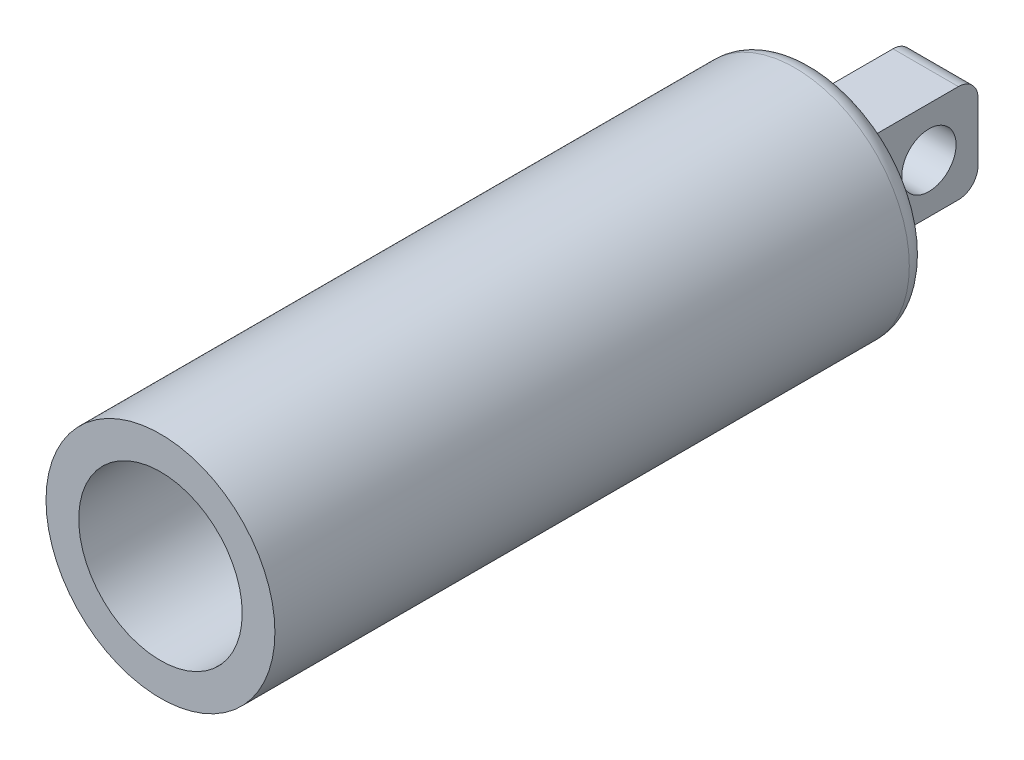
from build123d import *

# Parameters (mm, degrees)
SKETCH1_R                = 17.5
BOSS_EXTRUDE1_DEPTH      = 100
SKETCH2_R                = 12.5
CUT_EXTRUDE1_DEPTH       = 90
BOSS_EXTRUDE2_DEPTH      = 5
BOSS_EXTRUDE2_DEPTH_BACK = 5
SKETCH3_W                = 20
SKETCH3_H                = 15
SKETCH3_R                = 4.15
FILLET1_R                = 3


with BuildPart() as part:
    # Sketch1 → Boss-Extrude1 (new body)
    with BuildSketch(Plane.XY):
        Circle(SKETCH1_R)
    extrude(amount=BOSS_EXTRUDE1_DEPTH)

    # Sketch2 → Cut-Extrude1 (cut)
    with BuildSketch(Plane.XY.offset(100)):
        Circle(SKETCH2_R)
    extrude(amount=-CUT_EXTRUDE1_DEPTH, mode=Mode.SUBTRACT)

    # Sketch3 → Boss-Extrude2 (add, two sides: drawn at the far end of the back side and taken through both)
    with BuildSketch(Plane(origin=(0, 0, 0), x_dir=(0, 0, -1), z_dir=(1, 0, 0)).offset(-BOSS_EXTRUDE2_DEPTH_BACK)):
        with Locations((10, 0)):
            Rectangle(SKETCH3_W, SKETCH3_H)
        with Locations((12.5, 0)):
            Circle(SKETCH3_R, mode=Mode.SUBTRACT)
    extrude(amount=BOSS_EXTRUDE2_DEPTH + BOSS_EXTRUDE2_DEPTH_BACK)

    # Fillet1
    fillet1_edges = [part.edges().sort_by_distance(p)[0] for p in [
        (0, -7.5, 0),
        (-17.5, 0, 0),
        (0, -7.5, -20),
        (-5, 0, 0),
        (0, 7.5, -20),
        (5, 0, 0),
        (0, 7.5, 0),
    ]]
    fillet(fillet1_edges, radius=FILLET1_R)


solid = part.part
